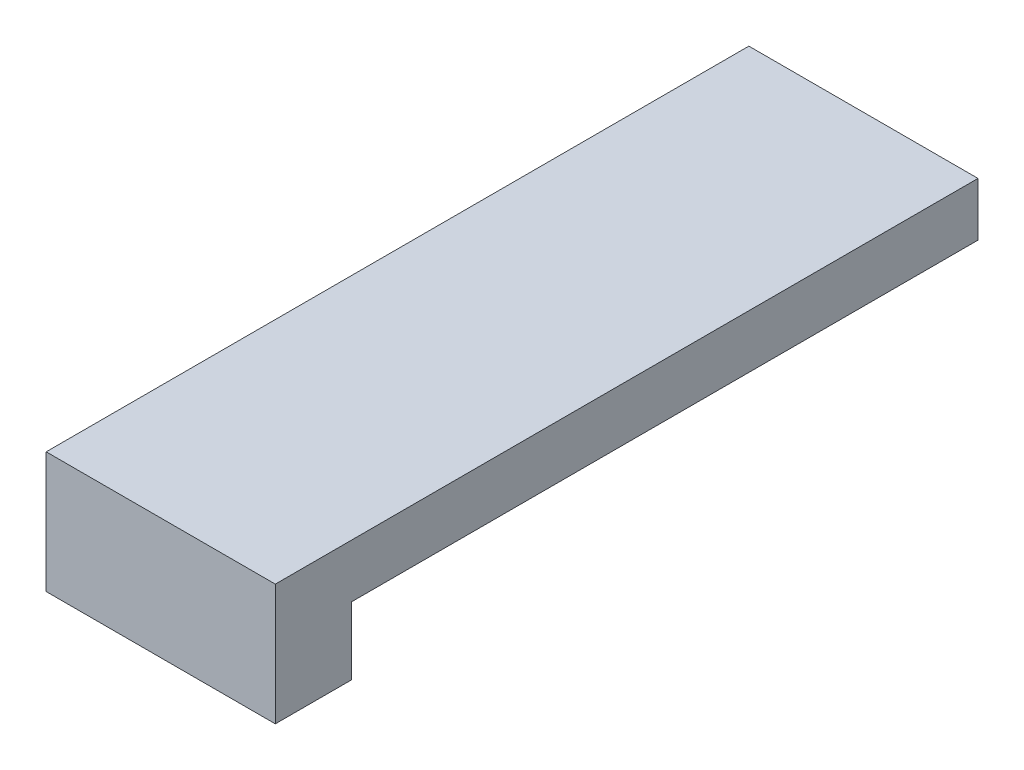
from build123d import *

# Parameters (mm, degrees)
CROQUIS1_W              = 15
CROQUIS1_H              = 3.5
SALIENTE_EXTRUIR1_DEPTH = 41
SALIENTE_EXTRUIR3_DEPTH = 5


with BuildPart() as part:
    # Croquis1 → Saliente-Extruir1 (new body)
    with BuildSketch(Plane.XY):
        with Locations((-23.589562337, 23.303225109)):
            Rectangle(CROQUIS1_W, CROQUIS1_H)
    extrude(amount=SALIENTE_EXTRUIR1_DEPTH)

    # Croquis2 → Saliente-Extruir3 (add)
    with BuildSketch(Plane.XY.offset(41)):
        Polygon((-31.089562337, 25.053225109), (-31.101471771, 17.12903643), (-16.089562337, 17.12903643), (-16.089562337, 25.053225109), align=None)
    extrude(amount=SALIENTE_EXTRUIR3_DEPTH)


solid = part.part
